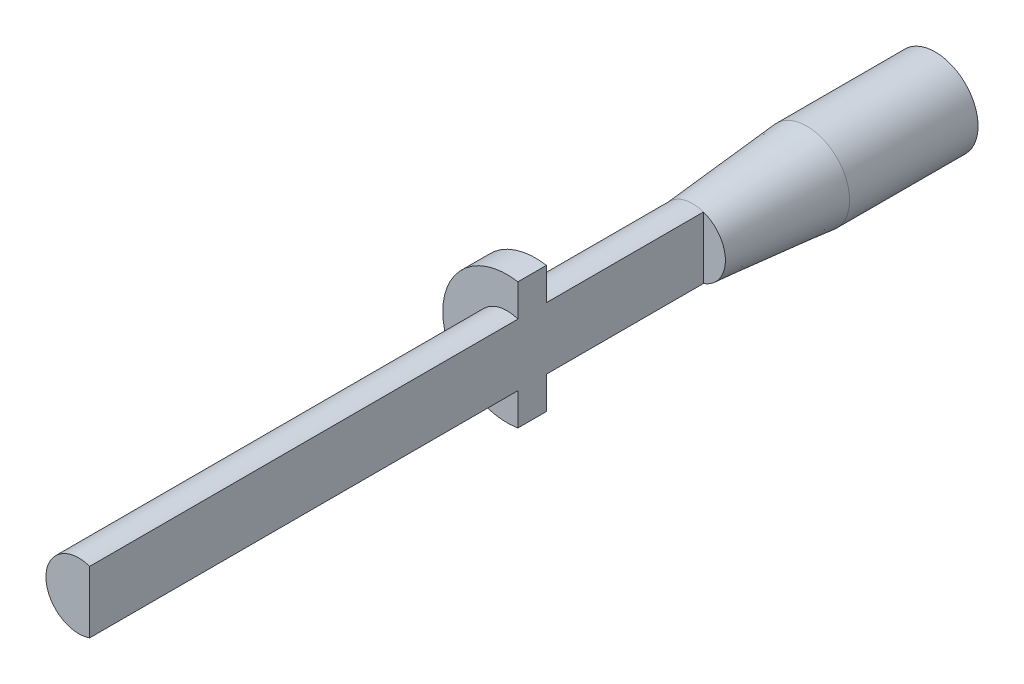
from build123d import *

# Parameters (mm, degrees)
BOSS_EXTRUDE2_DEPTH      = 2
BOSS_EXTRUDE3_DEPTH      = 30
BOSS_EXTRUDE3_DEPTH_BACK = 30
SKETCH3_R                = 3
BOSS_EXTRUDE4_DEPTH      = 17
CUT_EXTRUDE1_DEPTH       = 7.5


with BuildPart() as part:
    # Sketch2 → Boss-Extrude2 (new body)
    with BuildSketch(Plane.XY):
        with BuildLine():
            Line((0.762299154, -4.434963359), (0.762299154, 4.434963359))
            ThreePointArc((0.762299154, 4.434963359), (-4.5, 0), (0.762299154, -4.434963359))
        make_face()
    extrude(amount=-BOSS_EXTRUDE2_DEPTH)

    # Sketch1 → Boss-Extrude3 (add, two sides)
    with BuildSketch(Plane.XY) as boss_extrude3_sk:
        with BuildLine():
            Line((0.762299154, -2.17), (0.762299154, 2.17))
            ThreePointArc((0.762299154, 2.17), (-2.3, 0), (0.762299154, -2.17))
        make_face()
    extrude(amount=BOSS_EXTRUDE3_DEPTH)
    extrude(boss_extrude3_sk.sketch, amount=-BOSS_EXTRUDE3_DEPTH_BACK)

    # Sketch3 → Boss-Extrude4 (add)
    with BuildSketch(Plane(origin=(0, 0, -30), x_dir=(-1, 0, 0), z_dir=(0, 0, -1))):
        Circle(SKETCH3_R)
    extrude(amount=-BOSS_EXTRUDE4_DEPTH)

    # Sketch4 → Cut-Extrude1 (cut)
    with BuildSketch(Plane(origin=(0, 0, -30), x_dir=(-1, 0, 0), z_dir=(0, 0, -1))):
        with BuildLine():
            Line((-1.59, 1.409796085), (-1.59, -1.409796085))
            ThreePointArc((-1.59, -1.409796085), (2.125, 0), (-1.59, 1.409796085))
        make_face()
    extrude(amount=-CUT_EXTRUDE1_DEPTH, mode=Mode.SUBTRACT)

    # Sketch7 → Cut-Revolve1 (revolve, cut)
    with BuildSketch(Plane(origin=(0, 0, 0), x_dir=(0, 0, -1), z_dir=(1, 0, 0))):
        Polygon((13, 3), (21, 3), (13, 2.3), align=None)
    revolve(axis=Axis((0, 0, 30.362206594), (0, 0, -1)), mode=Mode.SUBTRACT)


solid = part.part
